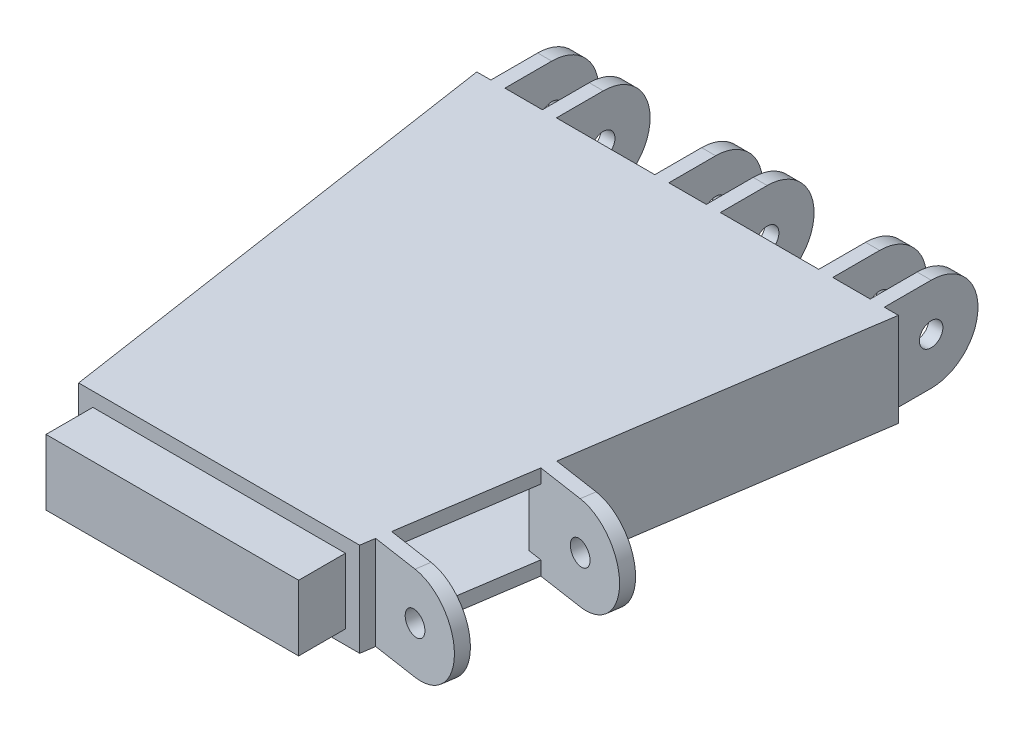
from build123d import *

# Parameters (mm, degrees)
BOSS_EXTRUDE1_DEPTH = 10
BOSS_EXTRUDE2_START = 35
SKETCH2_R           = 2.5
BOSS_EXTRUDE2_DEPTH = 7
LPATTERN1_COUNT     = 3
LPATTERN1_PITCH     = 35
SHELL1_T            = -3
SKETCH3_W           = 8
SKETCH3_H           = 20
CUT_EXTRUDE1_DEPTH  = 20
BOSS_EXTRUDE3_START = -3
SKETCH5_R           = 2.5
BOSS_EXTRUDE3_DEPTH = 3
LPATTERN2_COUNT     = 2
LPATTERN2_PITCH     = 31
SKETCH6_W           = 28
SKETCH6_H           = 14
CUT_EXTRUDE2_DEPTH  = 3
SKETCH7_W           = 53.932875476
SKETCH7_H           = 14
BOSS_EXTRUDE4_DEPTH = 10


with BuildPart() as part:
    # Sketch1 → Boss-Extrude1 (new body, symmetric)
    with BuildSketch(Plane(origin=(0, 0, 0), x_dir=(1, 0, 0), z_dir=(0, 1, 0))):
        Polygon((-45, 0), (45, 0), (30, -100), (-30, -100), align=None)
    extrude(amount=BOSS_EXTRUDE1_DEPTH, both=True)

    # Sketch2 → Boss-Extrude2 (add, symmetric)
    with BuildSketch(Plane(origin=(0, 0, 0), x_dir=(0, 0, -1), z_dir=(1, 0, 0)).offset(BOSS_EXTRUDE2_START)):
        with BuildLine():
            Line((0, 10), (10, 10))
            ThreePointArc((10, 10), (20, 0), (10, -10))
            Line((10, -10), (0, -10))
            Line((0, -10), (0, 10))
        make_face()
        with Locations((10, 0)):
            Circle(SKETCH2_R, mode=Mode.SUBTRACT)
    boss_extrude2 = extrude(amount=BOSS_EXTRUDE2_DEPTH, both=True)

    # LPattern1: Boss-Extrude2 ×3
    with Locations(*[(-i * LPATTERN1_PITCH, 0, 0) for i in range(1, LPATTERN1_COUNT)]):
        add(boss_extrude2)

    # Shell1
    shell1_openings = [part.faces().sort_by_distance(p)[0] for p in [
        (0, 0, 100),
    ]]
    offset(amount=SHELL1_T, openings=shell1_openings, kind=Kind.INTERSECTION)

    # Sketch3 → Cut-Extrude1 (cut)
    with BuildSketch(Plane.XY):
        with Locations((35, 0)):
            Rectangle(SKETCH3_W, SKETCH3_H)
        Rectangle(SKETCH3_W, SKETCH3_H)
        with Locations((-35, 0)):
            Rectangle(SKETCH3_W, SKETCH3_H)
    extrude(amount=-CUT_EXTRUDE1_DEPTH, mode=Mode.SUBTRACT)

    # Sketch5 → Boss-Extrude3 (add)
    with BuildSketch(Plane(origin=(-14.009779951, 0, 93.398533007), x_dir=(0.988936353, 0, 0.148340453), z_dir=(-0.148340453, 0, 0.988936353)).offset(BOSS_EXTRUDE3_START)):
        with BuildLine():
            Line((44.502135879, 10), (54.502135879, 10))
            ThreePointArc((54.502135879, 10), (64.502135879, 0), (54.502135879, -10))
            Line((54.502135879, -10), (44.502135879, -10))
            Line((44.502135879, -10), (44.502135879, 10))
        make_face()
        with Locations((54.502135879, 0)):
            Circle(SKETCH5_R, mode=Mode.SUBTRACT)
    boss_extrude3 = extrude(amount=-BOSS_EXTRUDE3_DEPTH)

    # LPattern2: Boss-Extrude3 ×2
    with Locations(*[Vector(0.148340453, 0, -0.988936353) * (i * LPATTERN2_PITCH) for i in range(1, LPATTERN2_COUNT)]):
        add(boss_extrude3)

    # Sketch6 → Cut-Extrude2 (cut)
    with BuildSketch(Plane(origin=(44.009779951, 0, 6.601466993), x_dir=(0.148340453, 0, -0.988936353), z_dir=(0.988936353, 0, 0.148340453))):
        with Locations((-74.443421699, 0)):
            Rectangle(SKETCH6_W, SKETCH6_H)
    extrude(amount=-CUT_EXTRUDE2_DEPTH, mode=Mode.SUBTRACT)


with BuildPart() as body_2:
    # Sketch7 → Boss-Extrude4 (new body)
    with BuildSketch(Plane.XY.offset(100)):
        Rectangle(SKETCH7_W, SKETCH7_H)
    extrude(amount=BOSS_EXTRUDE4_DEPTH)


solid = Compound([part.part, body_2.part])
